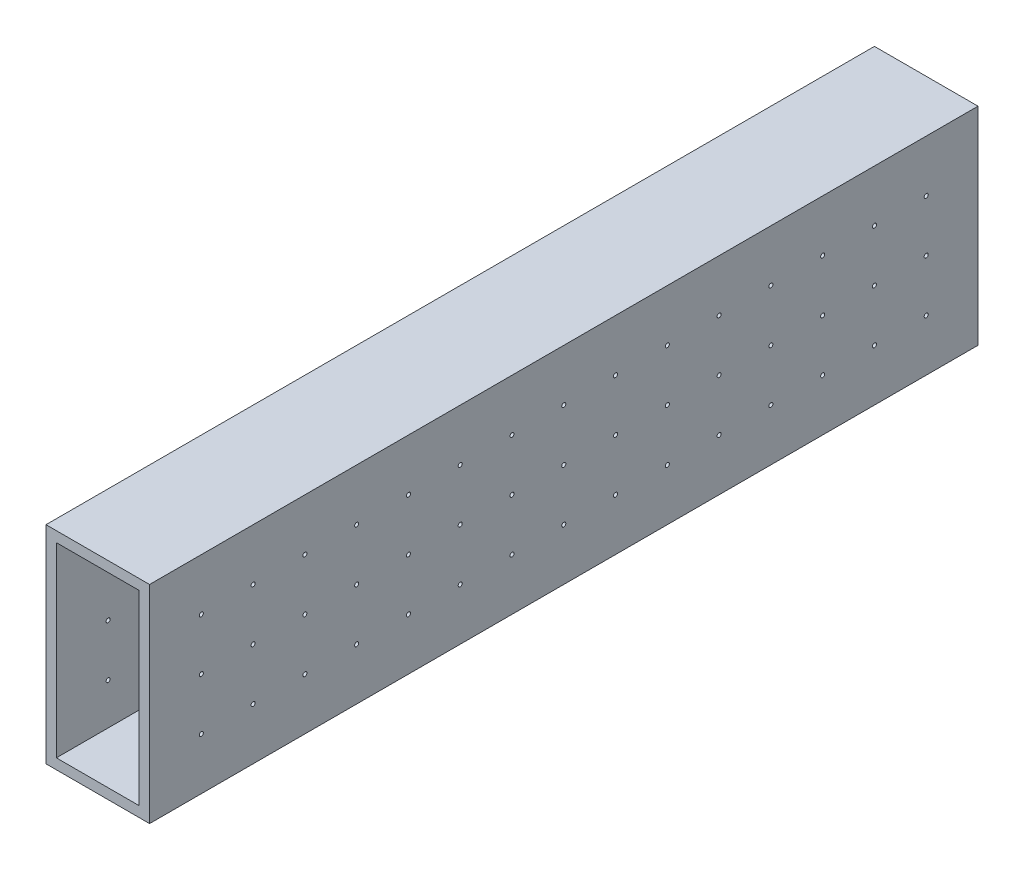
from build123d import *

# Parameters (mm, degrees)
SKETCH1_W           = 25.4
SKETCH1_H           = 50.8
SKETCH1_W_2         = 20.32
SKETCH1_H_2         = 45.72
BOSS_EXTRUDE1_DEPTH = 203.2
SKETCH2_R           = 0.5
CUT_EXTRUDE1_DEPTH  = 26.4


with BuildPart() as part:
    # Sketch1 → Boss-Extrude1 (new body)
    with BuildSketch(Plane.XY):
        with Locations((16.665400844, -8.681012658)):
            Rectangle(SKETCH1_W, SKETCH1_H)
        with Locations((16.665400844, -8.681012658)):
            Rectangle(SKETCH1_W_2, SKETCH1_H_2, mode=Mode.SUBTRACT)
    extrude(amount=BOSS_EXTRUDE1_DEPTH)

    # Sketch2 → Cut-Extrude1 (cut, through all)
    with BuildSketch(Plane(origin=(29.365400844, 0, 0), x_dir=(0, 0, -1), z_dir=(1, 0, 0))):
        with Locations((-190.5, 4.018987342)):
            Circle(SKETCH2_R)
        with Locations((-177.8, 4.018987342)):
            Circle(SKETCH2_R)
        with Locations((-165.1, 4.018987342)):
            Circle(SKETCH2_R)
        with Locations((-152.4, 4.018987342)):
            Circle(SKETCH2_R)
        with Locations((-139.7, 4.018987342)):
            Circle(SKETCH2_R)
        with Locations((-127, 4.018987342)):
            Circle(SKETCH2_R)
        with Locations((-114.3, 4.018987342)):
            Circle(SKETCH2_R)
        with Locations((-101.6, 4.018987342)):
            Circle(SKETCH2_R)
        with Locations((-88.9, 4.018987342)):
            Circle(SKETCH2_R)
        with Locations((-76.2, 4.018987342)):
            Circle(SKETCH2_R)
        with Locations((-63.5, 4.018987342)):
            Circle(SKETCH2_R)
        with Locations((-50.8, 4.018987342)):
            Circle(SKETCH2_R)
        with Locations((-38.1, 4.018987342)):
            Circle(SKETCH2_R)
        with Locations((-25.4, 4.018987342)):
            Circle(SKETCH2_R)
        with Locations((-12.7, 4.018987342)):
            Circle(SKETCH2_R)
        with Locations((-177.8, -8.681012658)):
            Circle(SKETCH2_R)
        with Locations((-165.1, -8.681012658)):
            Circle(SKETCH2_R)
        with Locations((-152.4, -8.681012658)):
            Circle(SKETCH2_R)
        with Locations((-139.7, -8.681012658)):
            Circle(SKETCH2_R)
        with Locations((-127, -8.681012658)):
            Circle(SKETCH2_R)
        with Locations((-114.3, -8.681012658)):
            Circle(SKETCH2_R)
        with Locations((-101.6, -8.681012658)):
            Circle(SKETCH2_R)
        with Locations((-88.9, -8.681012658)):
            Circle(SKETCH2_R)
        with Locations((-76.2, -8.681012658)):
            Circle(SKETCH2_R)
        with Locations((-63.5, -8.681012658)):
            Circle(SKETCH2_R)
        with Locations((-50.8, -8.681012658)):
            Circle(SKETCH2_R)
        with Locations((-38.1, -8.681012658)):
            Circle(SKETCH2_R)
        with Locations((-25.4, -8.681012658)):
            Circle(SKETCH2_R)
        with Locations((-12.7, -8.681012658)):
            Circle(SKETCH2_R)
        with Locations((-177.8, -21.381012658)):
            Circle(SKETCH2_R)
        with Locations((-165.1, -21.381012658)):
            Circle(SKETCH2_R)
        with Locations((-152.4, -21.381012658)):
            Circle(SKETCH2_R)
        with Locations((-139.7, -21.381012658)):
            Circle(SKETCH2_R)
        with Locations((-127, -21.381012658)):
            Circle(SKETCH2_R)
        with Locations((-114.3, -21.381012658)):
            Circle(SKETCH2_R)
        with Locations((-101.6, -21.381012658)):
            Circle(SKETCH2_R)
        with Locations((-88.9, -21.381012658)):
            Circle(SKETCH2_R)
        with Locations((-76.2, -21.381012658)):
            Circle(SKETCH2_R)
        with Locations((-63.5, -21.381012658)):
            Circle(SKETCH2_R)
        with Locations((-50.8, -21.381012658)):
            Circle(SKETCH2_R)
        with Locations((-38.1, -21.381012658)):
            Circle(SKETCH2_R)
        with Locations((-25.4, -21.381012658)):
            Circle(SKETCH2_R)
        with Locations((-12.7, -21.381012658)):
            Circle(SKETCH2_R)
        with Locations((-190.5, -8.681012658)):
            Circle(SKETCH2_R)
        with Locations((-190.5, -21.381012658)):
            Circle(SKETCH2_R)
    extrude(amount=-CUT_EXTRUDE1_DEPTH, mode=Mode.SUBTRACT)


solid = part.part
